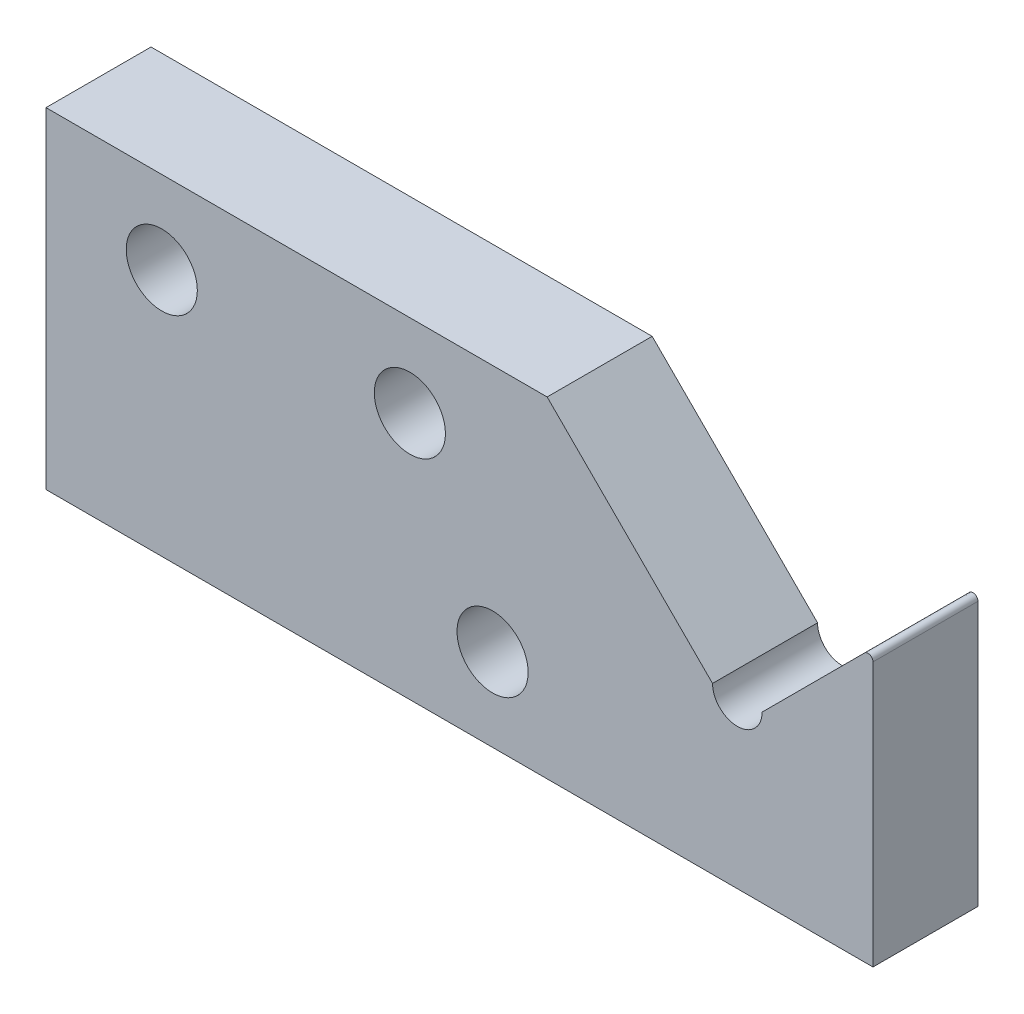
from build123d import *

# Parameters (mm, degrees)
SKETCH1_R                = 2.15
BOSS_EXTRUDE1_DEPTH      = 3.175
BOSS_EXTRUDE1_DEPTH_BACK = 3.175
SKETCH2_R                = 1.35
CUT_EXTRUDE1_DEPTH       = 20.866025
SKETCH3_R                = 1.6
CUT_EXTRUDE2_DEPTH       = 5
FILLET1_R                = 0.3


with BuildPart() as part:
    # Sketch1 → Boss-Extrude1 (new body, two sides)
    with BuildSketch(Plane.XY) as boss_extrude1_sk:
        with BuildLine():
            Line((-9.5, 164.786291501), (-59.5, 164.786291501))
            Line((-59.5, 164.786291501), (-59.5, 184.786291501))
            Line((-59.5, 184.786291501), (-29.2, 184.786291501))
            Line((-29.2, 184.786291501), (-19.2, 174.786291501))
            ThreePointArc((-19.2, 174.786291501), (-17.7, 173.286291501), (-16.2, 174.786291501))
            Line((-16.2, 174.786291501), (-9.5, 181.486291501))
            Line((-9.5, 181.486291501), (-9.5, 164.786291501))
        make_face()
        with Locations((-52.5, 179.786291501)):
            Circle(SKETCH1_R, mode=Mode.SUBTRACT)
        with Locations((-37.5, 179.786291501)):
            Circle(SKETCH1_R, mode=Mode.SUBTRACT)
        with Locations((-32.5, 169.786291501)):
            Circle(SKETCH1_R, mode=Mode.SUBTRACT)
    extrude(amount=BOSS_EXTRUDE1_DEPTH)
    extrude(boss_extrude1_sk.sketch, amount=-BOSS_EXTRUDE1_DEPTH_BACK)

    # Sketch2 → Cut-Extrude1 (cut)
    with BuildSketch(Plane.ZY.offset(59.5)):
        with Locations((0, 169.786291501)):
            Circle(SKETCH2_R)
    extrude(amount=-CUT_EXTRUDE1_DEPTH, mode=Mode.SUBTRACT)

    # Sketch3 → Cut-Extrude2 (cut)
    with BuildSketch(Plane.ZY.offset(59.5)):
        with Locations((0, 169.786291501)):
            Circle(SKETCH3_R)
    extrude(amount=-CUT_EXTRUDE2_DEPTH, mode=Mode.SUBTRACT)

    # Fillet1
    fillet1_edges = [part.edges().sort_by_distance(p)[0] for p in [
        (-9.5, 181.486291501, 0),
    ]]
    fillet(fillet1_edges, radius=FILLET1_R)


solid = part.part
